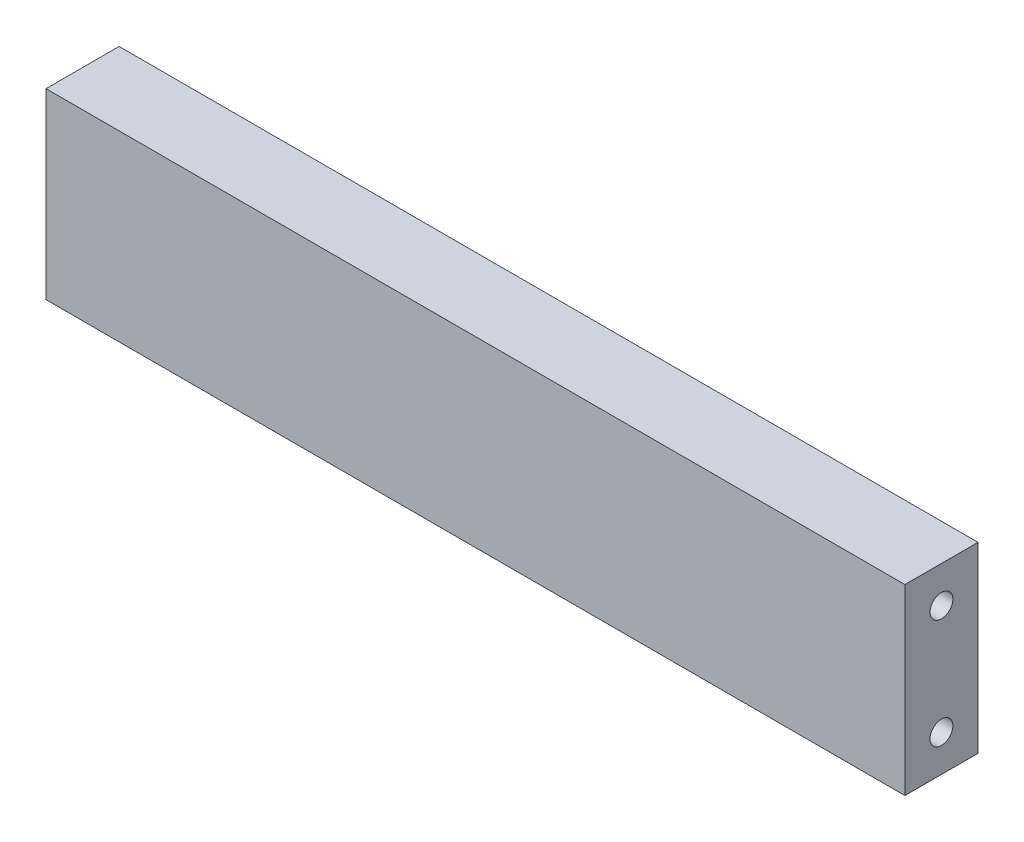
from build123d import *

# Parameters (mm, degrees)
SKETCH_1_W                      = 94
SKETCH_1_H                      = 20
EXTRUDE_1_DEPTH                 = 8
M3_HORIZONTALBAR_FIX_AT_2_COUNT = 2
M3_HORIZONTALBAR_FIX_AT_2_PITCH = 12


with BuildPart() as part:
    # 스케치1 → 보스-돌출1 (new body)
    with BuildSketch(Plane.XY):
        Rectangle(SKETCH_1_W, SKETCH_1_H)
    extrude(amount=EXTRUDE_1_DEPTH)

    # 스케치5 → M3-HORIZONTALBAR_FIX (revolve, cut)
    with BuildSketch(Plane(origin=(47, 6, 4), x_dir=(0, 0, -1), z_dir=(0, 1, 0))):
        Polygon((0, 0), (0, 9.251075774), (1.25, 8.5), (1.25, 0), align=None)
    m3_horizontalbar_fix = revolve(axis=Axis((53.35, 6, 4), (-1, 0, 0)), mode=Mode.SUBTRACT)

    # M3-HORIZONTALBAR_FIX at 2: M3-HORIZONTALBAR_FIX ×2
    with Locations(*[(0, -i * M3_HORIZONTALBAR_FIX_AT_2_PITCH, 0) for i in range(1, M3_HORIZONTALBAR_FIX_AT_2_COUNT)]):
        add(m3_horizontalbar_fix, mode=Mode.SUBTRACT)

    # 대칭 복사1: M3-HORIZONTALBAR_FIX across plane
    add(m3_horizontalbar_fix.mirror(Plane(origin=(0, 0, 0), x_dir=(0, 0, 1), z_dir=(1, 0, 0))), mode=Mode.SUBTRACT)

    # 대칭 복사1 copy 1 sketch → 대칭 복사1 copy 1 (revolve, cut)
    with BuildSketch(Plane(origin=(-47, -6, 4), x_dir=(0, 0, -1), z_dir=(0, 1, 0))):
        Polygon((0, 0), (0, -9.251075774), (1.25, -8.5), (1.25, 0), align=None)
    revolve(axis=Axis((-53.35, -6, 4), (-1, 0, 0)), mode=Mode.SUBTRACT)


solid = part.part
